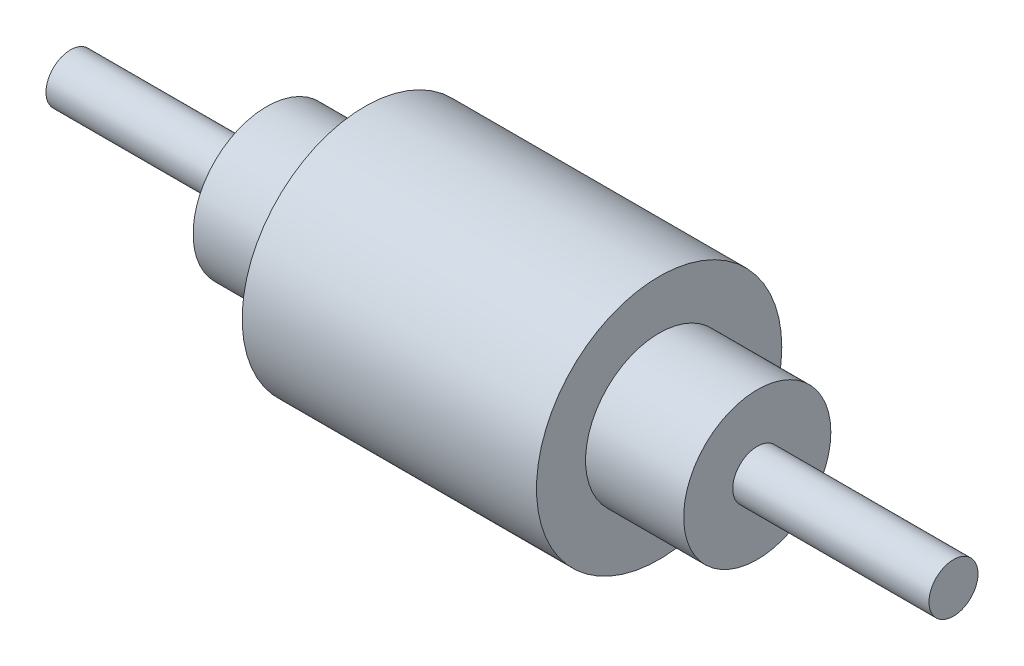
from build123d import *


with BuildPart() as part:
    # Sketch1 → Revolve1 (revolve)
    with BuildSketch(Plane.XY):
        Polygon((-180, 0), (0, 0), (0, 50), (-60, 50), (-60, 30), (-100, 30), (-100, 10), (-180, 10), align=None)
        Polygon((0, 0), (180, 0), (180, 10), (100, 10), (100, 30), (60, 30), (60, 50), (0, 50), align=None)
    revolve(axis=Axis((180, 0, 0), (-1, 0, 0)))


solid = part.part
